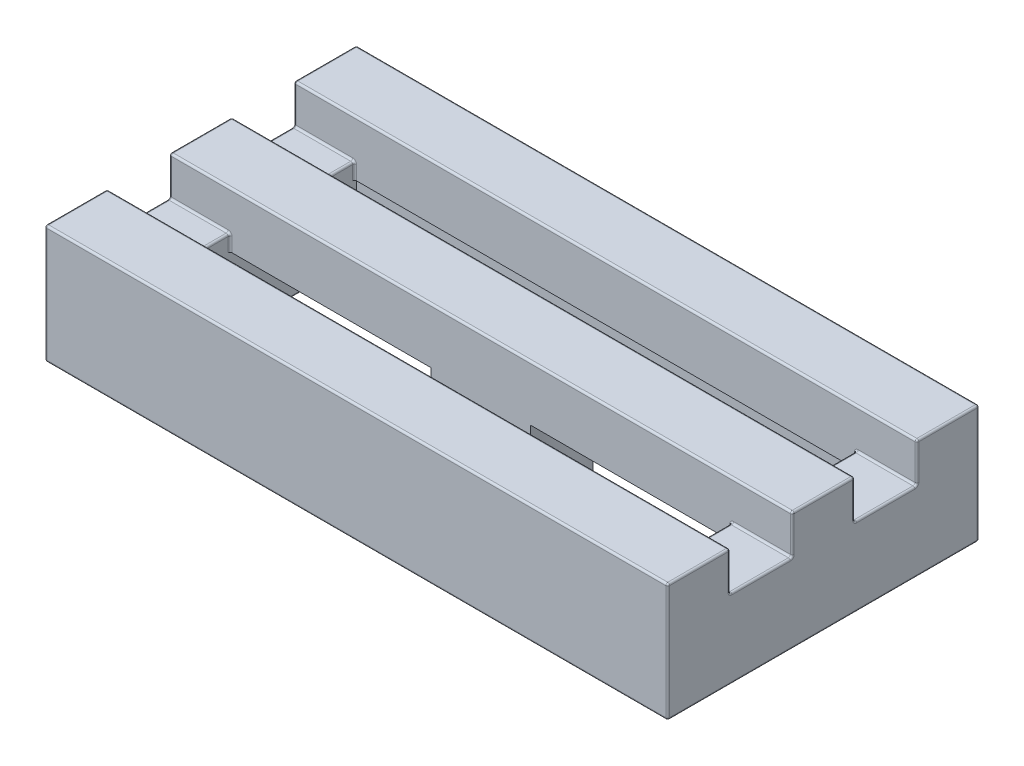
from build123d import *

# Parameters (mm, degrees)
SKETCH1_W       = 7.96
SKETCH1_H       = 7.96
EXTRUDE1_DEPTH  = 3.22
LPATTERN1_COUNT = 2
LPATTERN1_PITCH = 7.96
SHELL1_T        = -1.55
SKETCH4_W       = 12.82
SKETCH4_H       = 4.86
EXTRUDE3_DEPTH  = 0.14
SKETCH7_W       = 15.92
SKETCH7_H       = 7.96
SKETCH7_W_2     = 15.52
SKETCH7_H_2     = 7.56
EXTRUDE6_DEPTH  = 0.2
SKETCH5_R       = 1.5
EXTRUDE7_DEPTH  = 1.81
SKETCH8_W       = 1.592
SKETCH8_H       = 1
EXTRUDE8_DEPTH  = 16.92
SKETCH10_W      = 12.82
SKETCH10_H      = 1.592
EXTRUDE9_DEPTH  = 3.22
FILLET3_R       = 0.05


with BuildPart() as part:
    # Sketch1 → Extrude1 (new body)
    with BuildSketch(Plane(origin=(0, 0, 0), x_dir=(1, 0, 0), z_dir=(0, 1, 0))):
        Rectangle(SKETCH1_W, SKETCH1_H)
    extrude1 = extrude(amount=EXTRUDE1_DEPTH)

    # LPattern1: Extrude1 ×2
    with Locations(*[(i * LPATTERN1_PITCH, 0, 0) for i in range(1, LPATTERN1_COUNT)]):
        add(extrude1)

    # Shell1
    shell1_openings = [part.faces().sort_by_distance(p)[0] for p in [
        (3.98, 0, 0),
    ]]
    offset(amount=SHELL1_T, openings=shell1_openings, kind=Kind.INTERSECTION)

    # Sketch4 → Extrude3 (cut)
    with BuildSketch(Plane.XZ.offset(-1.67)):
        with Locations((3.98, 0)):
            Rectangle(SKETCH4_W, SKETCH4_H)
    extrude(amount=-EXTRUDE3_DEPTH, mode=Mode.SUBTRACT)

    # Sketch7 → Extrude6 (cut)
    with BuildSketch(Plane.XZ):
        with Locations((3.98, 0)):
            Rectangle(SKETCH7_W, SKETCH7_H)
        with Locations((3.98, 0)):
            Rectangle(SKETCH7_W_2, SKETCH7_H_2, mode=Mode.SUBTRACT)
    extrude(amount=-EXTRUDE6_DEPTH, mode=Mode.SUBTRACT)

    # Sketch5 → Extrude7 (add)
    with BuildSketch(Plane.XZ.offset(-1.81)):
        with Locations((3.98, 0)):
            Circle(SKETCH5_R)
    extrude(amount=EXTRUDE7_DEPTH)

    # Sketch8 → Extrude8 (cut, through all)
    with BuildSketch(Plane(origin=(11.94, 0, 0), x_dir=(0, 0, -1), z_dir=(1, 0, 0))):
        with Locations((1.592, 2.72)):
            Rectangle(SKETCH8_W, SKETCH8_H)
        with Locations((-1.592, 2.72)):
            Rectangle(SKETCH8_W, SKETCH8_H)
    extrude(amount=-EXTRUDE8_DEPTH, mode=Mode.SUBTRACT)

    # Sketch10 → Extrude9 (cut, through all)
    with BuildSketch(Plane(origin=(0, 2.22, 0), x_dir=(1, 0, 0), z_dir=(0, 1, 0))):
        with Locations((3.98, 1.592)):
            Rectangle(SKETCH10_W, SKETCH10_H)
        with Locations((3.98, -1.592)):
            Rectangle(SKETCH10_W, SKETCH10_H)
    extrude(amount=-EXTRUDE9_DEPTH, mode=Mode.SUBTRACT)

    # Fillet3
    fillet3_edges = [part.edges().sort_by_distance(p)[0] for p in [
        (-3.98, 3.22, -3.184),
        (11.165, 2.22, -0.796),
        (11.165, 2.22, -2.388),
        (-2.43, 2.015, -0.796),
        (-2.43, 2.015, -2.388),
        (10.39, 2.015, -2.388),
        (10.39, 2.015, -0.796),
        (-2.43, 2.22, -1.592),
        (10.39, 2.22, -1.592),
        (3.98, 3.22, 3.98),
        (11.165, 2.22, 2.388),
        (11.165, 2.22, 0.796),
        (11.94, 1.71, 3.98),
        (11.94, 1.71, -3.98),
        (-2.43, 2.015, 2.388),
        (-2.43, 2.015, 0.796),
        (10.39, 2.015, 0.796),
        (10.39, 2.015, 2.388),
        (-2.43, 2.22, 1.592),
        (10.39, 2.22, 1.592),
        (11.94, 3.22, 3.184),
        (3.98, 0, -2.43),
        (-2.43, 0, 0),
        (3.98, 0, 2.43),
        (10.39, 0, 0),
        (3.98, 0.2, 3.98),
        (11.94, 0.2, 0),
        (3.98, 0.2, -3.98),
        (-3.98, 0.2, 0),
        (3.98, 0.2, 3.78),
        (-3.78, 0.2, 0),
        (3.98, 0.2, -3.78),
        (11.74, 0.2, 0),
        (3.98, 0, 3.78),
        (11.74, 0.1, 3.78),
        (11.74, 0, 0),
        (11.74, 0.1, -3.78),
        (3.98, 0, -3.78),
        (-3.78, 0.1, -3.78),
        (-3.78, 0, 0),
        (-3.78, 0.1, 3.78),
        (3.98, 3.22, -3.98),
        (-3.98, 1.71, 3.98),
        (-3.98, 1.71, -3.98),
        (-3.98, 3.22, 0),
        (11.94, 3.22, -3.184),
        (-3.98, 2.72, -2.388),
        (3.98, 3.22, -2.388),
        (-3.98, 2.22, -1.592),
        (-3.205, 2.22, -2.388),
        (-3.98, 2.72, -0.796),
        (-3.205, 2.22, -0.796),
        (3.98, 3.22, -0.796),
        (11.94, 2.72, -2.388),
        (11.94, 2.72, -0.796),
        (11.94, 2.22, -1.592),
        (-3.98, 3.22, 3.184),
        (11.94, 3.22, 0),
        (-3.98, 2.72, 0.796),
        (3.98, 3.22, 0.796),
        (-3.98, 2.22, 1.592),
        (-3.205, 2.22, 0.796),
        (-3.98, 2.72, 2.388),
        (-3.205, 2.22, 2.388),
        (3.98, 3.22, 2.388),
        (11.94, 2.72, 0.796),
        (11.94, 2.72, 2.388),
        (11.94, 2.22, 1.592),
    ]]
    fillet(fillet3_edges, radius=FILLET3_R)


solid = part.part
